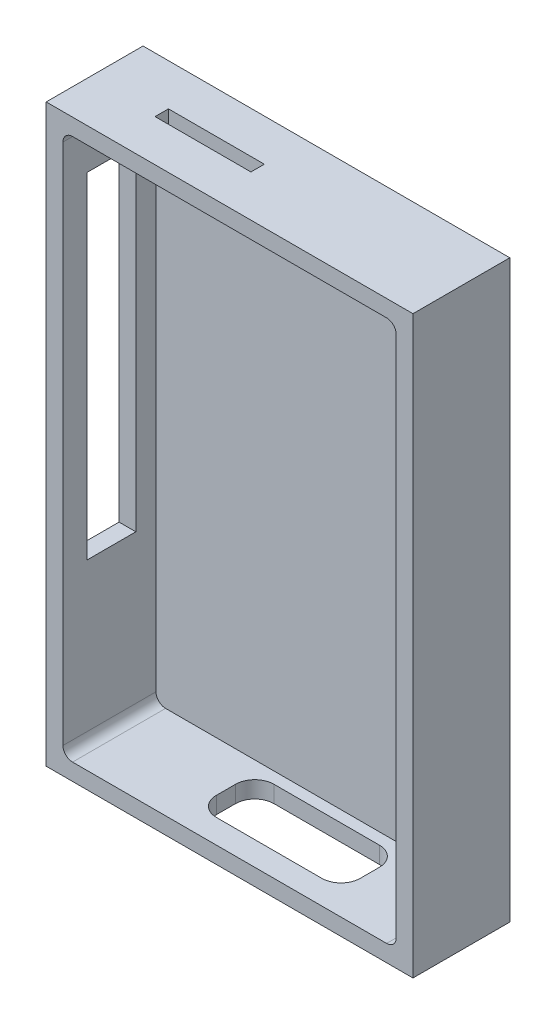
from build123d import *

# Parameters (mm, degrees)
SKETCH_1_W          = 76.5
SKETCH_1_H          = 120
EXTRUDE_1_DEPTH     = 0.8
SKETCH_10_W         = 76.5
SKETCH_10_H         = 120
SKETCH_10_W_2       = 69.5
SKETCH_10_H_2       = 113
EXTRUDE_2_DEPTH     = 19.4
FILLET_1_R          = 2
SKETCH_11_W         = 10.2
SKETCH_11_H         = 70
CUT_EXTRUDE_1_DEPTH = 3.5
SKETCH_12_W         = 30
SKETCH_12_H         = 12
CUT_EXTRUDE_2_DEPTH = 10
FILLET_2_R          = 4
CUT_EXTRUDE_3_REACH = 122
SKETCH_13_W         = 20
SKETCH_13_H         = 2.8


with BuildPart() as part:
    # ｽｹｯﾁ1 → ﾎﾞｽ - 押し出し1 (new body)
    with BuildSketch(Plane.XY):
        with Locations((38.25, 60)):
            Rectangle(SKETCH_1_W, SKETCH_1_H)
    extrude(amount=EXTRUDE_1_DEPTH)

    # ｽｹｯﾁ10 → ﾎﾞｽ - 押し出し2 (add)
    with BuildSketch(Plane.XY.offset(0.8)):
        with Locations((38.25, 60)):
            Rectangle(SKETCH_10_W, SKETCH_10_H)
        with Locations((38.25, 60)):
            Rectangle(SKETCH_10_W_2, SKETCH_10_H_2, mode=Mode.SUBTRACT)
    extrude(amount=EXTRUDE_2_DEPTH)

    # ﾌｨﾚｯﾄ1
    fillet_1_edges = [part.edges().sort_by_distance(p)[0] for p in [
        (73, 116.5, 10.5),
        (3.5, 116.5, 10.5),
        (3.5, 3.5, 10.5),
        (73, 3.5, 10.5),
    ]]
    fillet(fillet_1_edges, radius=FILLET_1_R)

    # ｽｹｯﾁ11 → ｶｯﾄ - 押し出し1 (cut)
    with BuildSketch(Plane.ZY):
        with Locations((10.1, 71.5)):
            Rectangle(SKETCH_11_W, SKETCH_11_H)
    extrude(amount=-CUT_EXTRUDE_1_DEPTH, mode=Mode.SUBTRACT)

    # ｽｹｯﾁ12 → ｶｯﾄ - 押し出し2 (cut)
    with BuildSketch(Plane(origin=(0, 0, 0), x_dir=(-1, 0, 0), z_dir=(0, -1, 0))):
        with Locations((-41.5, -9.2)):
            Rectangle(SKETCH_12_W, SKETCH_12_H)
    extrude(amount=-CUT_EXTRUDE_2_DEPTH, mode=Mode.SUBTRACT)

    # ﾌｨﾚｯﾄ2
    fillet_2_edges = [part.edges().sort_by_distance(p)[0] for p in [
        (56.5, 1.75, 15.2),
        (56.5, 1.75, 3.2),
        (26.5, 1.75, 3.2),
        (26.5, 1.75, 15.2),
    ]]
    fillet(fillet_2_edges, radius=FILLET_2_R)

    # ｽｹｯﾁ13 → ｶｯﾄ - 押し出し3 (cut, up to next)
    with BuildSketch(Plane(origin=(0, 120, 0), x_dir=(1, 0, 0), z_dir=(0, 1, 0)), mode=Mode.PRIVATE) as cut_extrude_3_sk1:
        with Locations((24, -10.1)):
            Rectangle(SKETCH_13_W, SKETCH_13_H)
    cut_extrude_3_tool1 = extrude(cut_extrude_3_sk1.sketch, amount=-CUT_EXTRUDE_3_REACH, mode=Mode.PRIVATE) & part.part
    add(cut_extrude_3_tool1.solids().sort_by_distance((24, 120, 10.1))[0], mode=Mode.SUBTRACT)


solid = part.part
